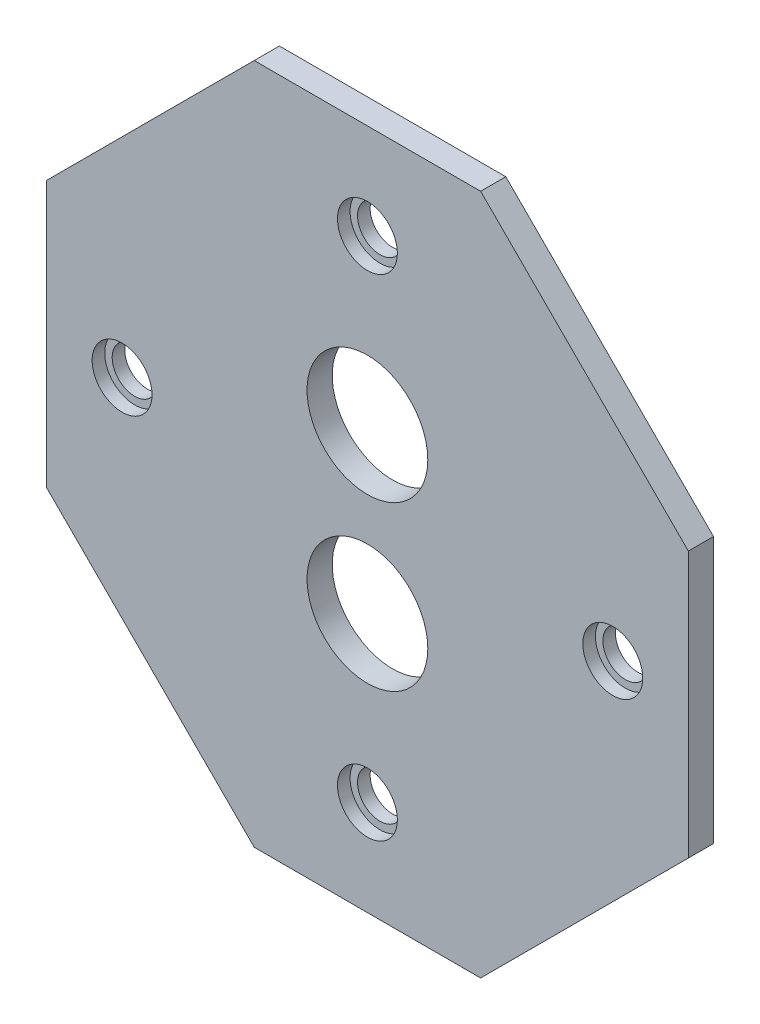
from build123d import *

# Parameters (mm, degrees)
SKETCH2_R           = 4.7625
SKETCH2_R_2         = 12.8
BOSS_EXTRUDE2_DEPTH = 5.334
CUT_EXTRUDE3_START  = -2.667
SKETCH3_R           = 6.35
SKETCH3_R_2         = 4.7625
CUT_EXTRUDE3_DEPTH  = 2.667
SKETCH3_2_R         = 4.7625
CUT_EXTRUDE4_DEPTH  = 142.745248595


with BuildPart() as part:
    # Sketch2 → Boss-Extrude2 (new body)
    with BuildSketch(Plane.XY):
        Polygon((-68.038646731, 23.829969758), (-24, -20.208676973), (24, -20.208676973), (68.038646731, 23.829969758), (68.038646731, 80.195030242), (24, 124.233676973), (-24, 124.233676973), (-68.038646731, 80.195030242), align=None)
        Circle(SKETCH2_R, mode=Mode.SUBTRACT)
        with Locations((0, 34.675)):
            Circle(SKETCH2_R_2, mode=Mode.SUBTRACT)
        with Locations((0, 69.35)):
            Circle(SKETCH2_R_2, mode=Mode.SUBTRACT)
    extrude(amount=BOSS_EXTRUDE2_DEPTH)

    # Sketch3 → Cut-Extrude3 (cut)
    # profile 1 of 4: a face of its own
    with BuildSketch(Plane.XY.offset(5.334).offset(CUT_EXTRUDE3_START)):
        Circle(SKETCH3_R)
        Circle(SKETCH3_R_2, mode=Mode.SUBTRACT)
    # profile 2 of 4: a face of its own
    with BuildSketch(Plane.XY.offset(5.334).offset(CUT_EXTRUDE3_START)):
        with Locations((52.0125, 52.0125)):
            Circle(SKETCH3_R)
        with Locations((52.0125, 52.0125)):
            Circle(SKETCH3_R_2, mode=Mode.SUBTRACT)
    # profile 3 of 4: a face of its own
    with BuildSketch(Plane.XY.offset(5.334).offset(CUT_EXTRUDE3_START)):
        with Locations((0, 104.025)):
            Circle(SKETCH3_R)
        with Locations((0, 104.025)):
            Circle(SKETCH3_R_2, mode=Mode.SUBTRACT)
    # profile 4 of 4: a face of its own
    with BuildSketch(Plane.XY.offset(5.334).offset(CUT_EXTRUDE3_START)):
        with Locations((-52.0125, 52.0125)):
            Circle(SKETCH3_R)
        with Locations((-52.0125, 52.0125)):
            Circle(SKETCH3_R_2, mode=Mode.SUBTRACT)
    extrude(amount=CUT_EXTRUDE3_DEPTH, mode=Mode.SUBTRACT)

    # Sketch3_2 → Cut-Extrude4 (cut, through all)
    with BuildSketch(Plane.XY.offset(5.334)):
        with Locations((52.0125, 52.0125)):
            Circle(SKETCH3_2_R)
        with Locations((0, 104.025)):
            Circle(SKETCH3_2_R)
        with Locations((-52.0125, 52.0125)):
            Circle(SKETCH3_2_R)
    extrude(amount=-CUT_EXTRUDE4_DEPTH, mode=Mode.SUBTRACT)


solid = part.part
